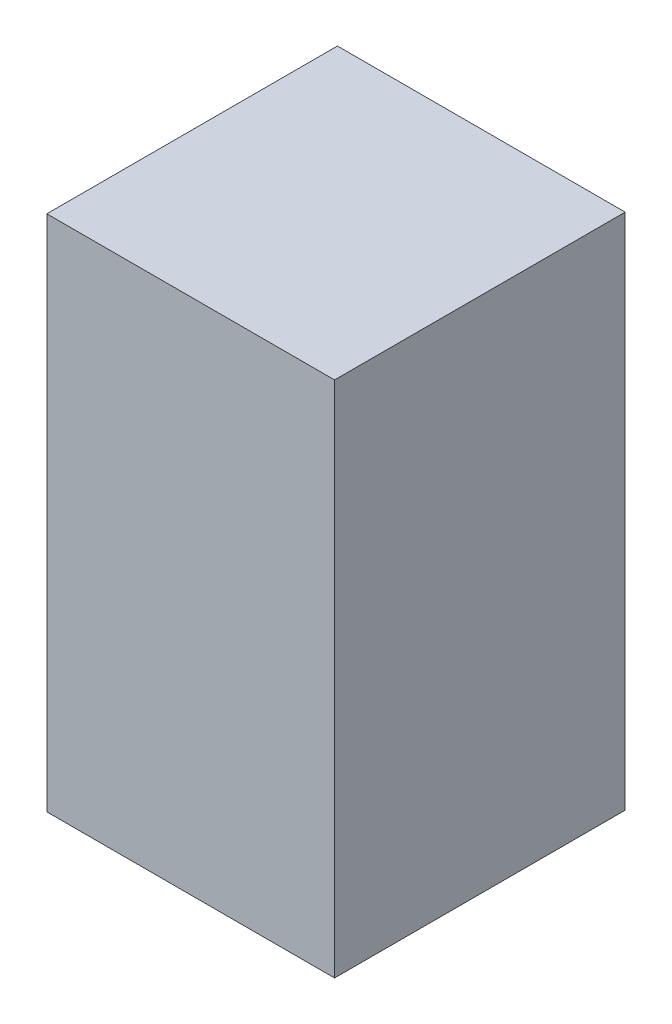
from build123d import *

# Parameters (mm, degrees)
SKETCH1_W           = 30
SKETCH1_H           = 54
BOSS_EXTRUDE1_DEPTH = 30.3


with BuildPart() as part:
    # Sketch1 → Boss-Extrude1 (new body)
    with BuildSketch(Plane.XY):
        Rectangle(SKETCH1_W, SKETCH1_H)
    extrude(amount=BOSS_EXTRUDE1_DEPTH)


solid = part.part
